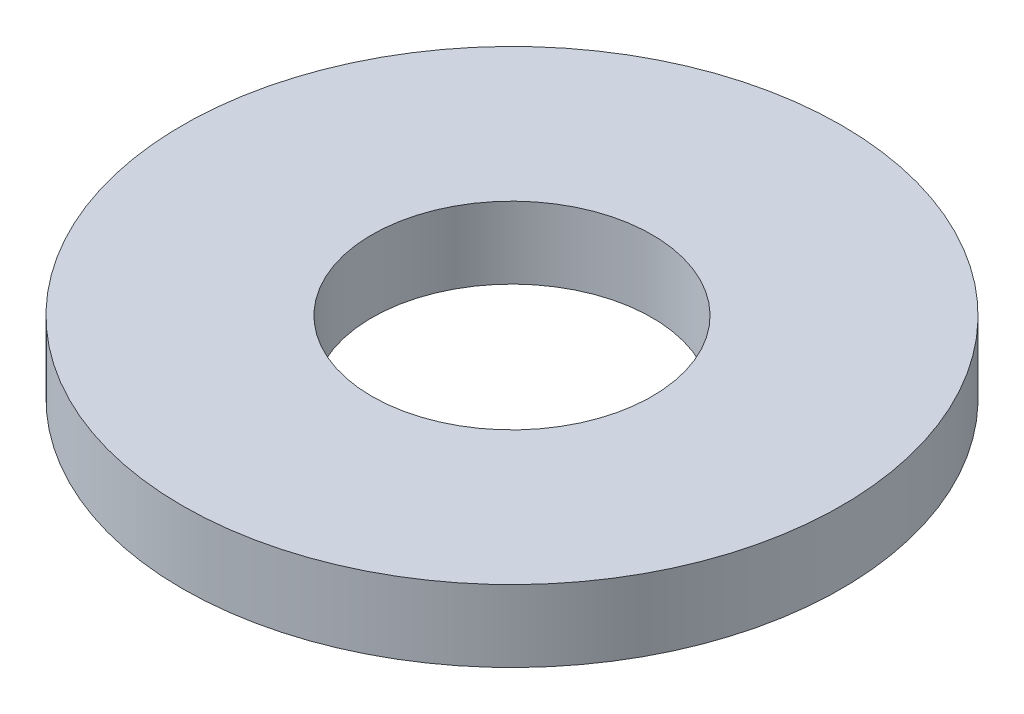
from build123d import *

# Parameters (mm, degrees)
SKETCH1_R           = 9.3218
BOSS_EXTRUDE1_DEPTH = 2.032
SKETCH5_R           = 3.9624
CUT_EXTRUDE1_DEPTH  = 3.032


with BuildPart() as part:
    # Sketch1 → Boss-Extrude1 (new body)
    with BuildSketch(Plane(origin=(0, 0, 0), x_dir=(1, 0, 0), z_dir=(0, 1, 0))):
        Circle(SKETCH1_R)
    extrude(amount=BOSS_EXTRUDE1_DEPTH)

    # Sketch5 → Cut-Extrude1 (cut, through all)
    with BuildSketch(Plane(origin=(0, 2.032, 0), x_dir=(-1, 0, 0), z_dir=(0, 1, 0))):
        Circle(SKETCH5_R)
    extrude(amount=-CUT_EXTRUDE1_DEPTH, mode=Mode.SUBTRACT)


solid = part.part
